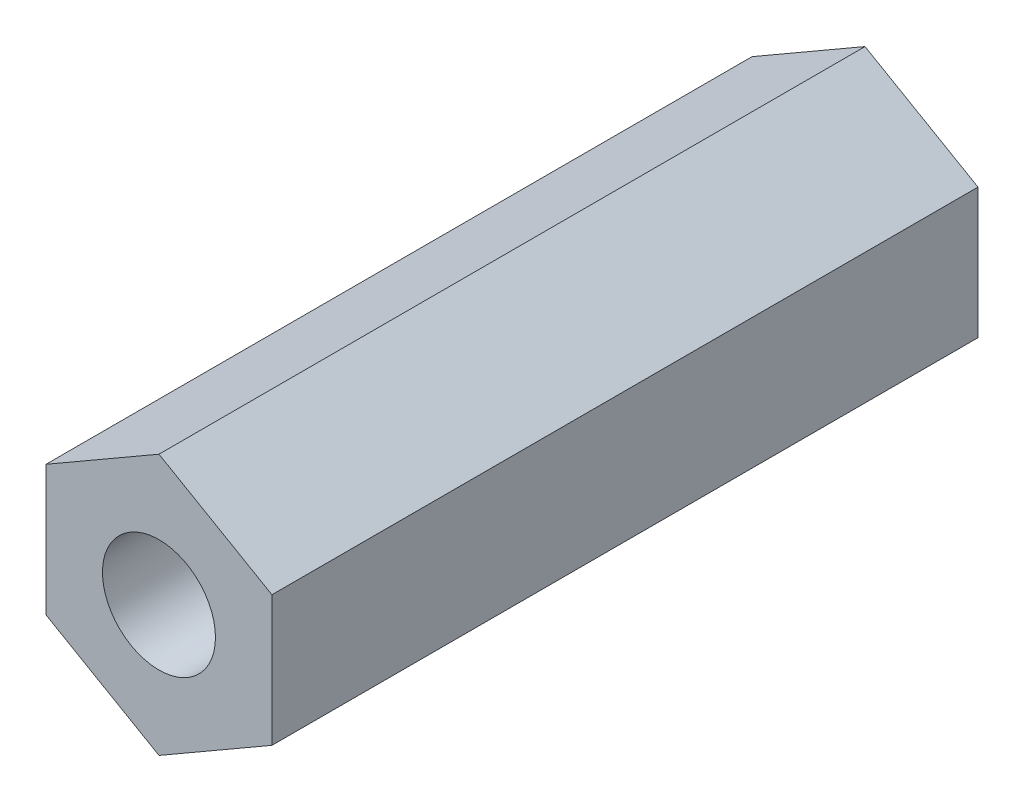
from build123d import *

# Parameters (mm, degrees)
ESQUISSE1_R        = 2
BOSS_EXTRU_1_DEPTH = 25


with BuildPart() as part:
    # Esquisse1 → Boss.-Extru.1 (new body)
    with BuildSketch(Plane.XY):
        Polygon((4, -2.309401077), (4, 2.309401077), (0, 4.618802154), (-4, 2.309401077), (-4, -2.309401077), (0, -4.618802154), align=None)
        Circle(ESQUISSE1_R, mode=Mode.SUBTRACT)
    extrude(amount=BOSS_EXTRU_1_DEPTH)


solid = part.part
